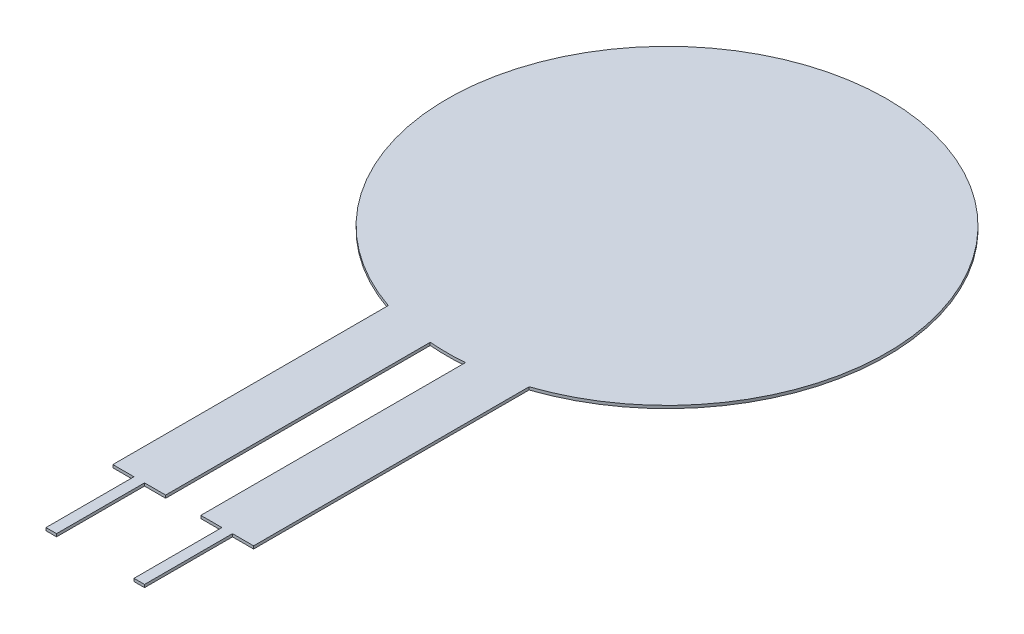
from build123d import *

# Parameters (mm, degrees)
BOSS_EXTRUDE1_DEPTH = 0.2032


with BuildPart() as part:
    # Sketch1 → Boss-Extrude1 (new body)
    with BuildSketch(Plane(origin=(0, 0, 0), x_dir=(1, 0, 0), z_dir=(0, 1, 0))):
        with BuildLine():
            Line((-1.27, -15.824118459), (-1.27, -34.925))
            Line((-1.27, -34.925), (-2.794, -34.925))
            Line((-2.794, -34.925), (-2.794, -41.275))
            Line((-2.794, -41.275), (-3.556, -41.275))
            Line((-3.556, -41.275), (-3.556, -34.925))
            Line((-3.556, -34.925), (-5.08, -34.925))
            Line((-5.08, -34.925), (-5.08, -15.294253489))
            Line((-5.08, -15.294253489), (-5.08, -15.040253489))
            ThreePointArc((-5.08, -15.040253489), (0, 15.875), (5.08, -15.040253489))
            Line((5.08, -15.040253489), (5.08, -15.294253489))
            Line((5.08, -15.294253489), (5.08, -34.925))
            Line((5.08, -34.925), (3.556, -34.925))
            Line((3.556, -34.925), (3.556, -41.275))
            Line((3.556, -41.275), (2.794, -41.275))
            Line((2.794, -41.275), (2.794, -34.925))
            Line((2.794, -34.925), (1.27, -34.925))
            Line((1.27, -34.925), (1.27, -15.824118459))
            ThreePointArc((1.27, -15.824118459), (0, -15.875), (-1.27, -15.824118459))
        make_face()
    extrude(amount=BOSS_EXTRUDE1_DEPTH)


solid = part.part
